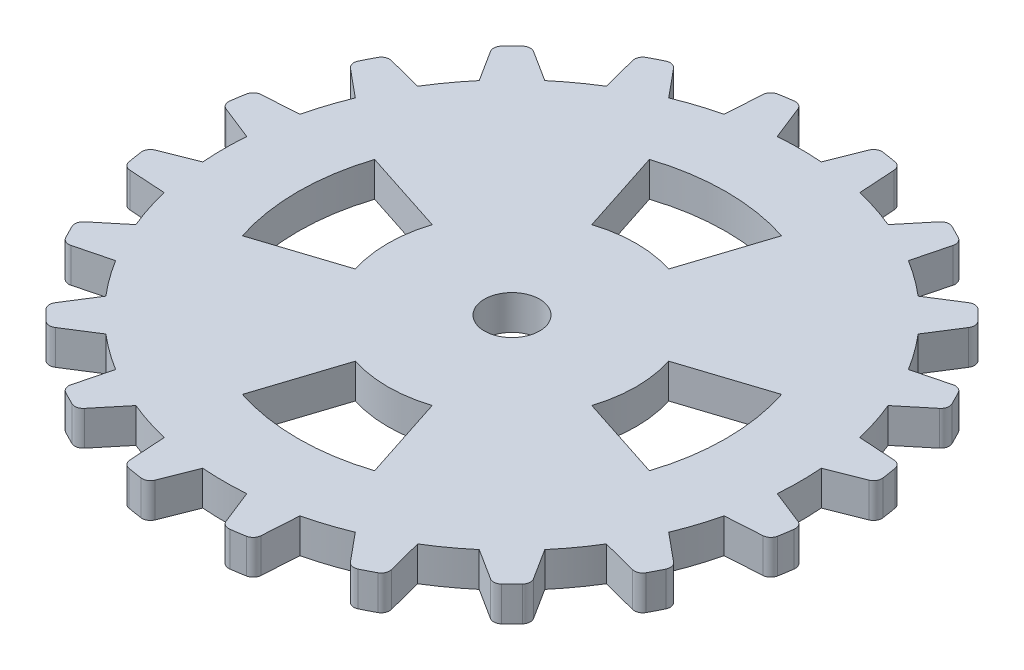
from build123d import *

# Parameters (mm, degrees)
BOSS_EXTRUDE1_DEPTH = 2.5
FILLET1_R           = 0.6
CUT_EXTRUDE1_DEPTH  = 3.5
SKETCH3_R           = 2
CUT_EXTRUDE2_DEPTH  = 3.5


with BuildPart() as part:
    # Sketch1 → Boss-Extrude1 (new body)
    with BuildSketch(Plane(origin=(0, 0, 0), x_dir=(1, 0, 0), z_dir=(0, 1, 0))):
        with BuildLine():
            Line((-1.594631361, 20.812249191), (-2.743922179, 23.715026443))
            ThreePointArc((-2.743922179, 23.715026443), (-3.734597528, 23.5793208), (-4.718721125, 23.402249017))
            Line((-4.718721125, 23.402249017), (-4.914754144, 20.286393402))
            ThreePointArc((-4.914754144, 20.286393402), (-6.450188978, 19.851640429), (-7.947923238, 19.300857021))
            Line((-7.947923238, 19.300857021), (-9.937971261, 21.706411848))
            ThreePointArc((-9.937971261, 21.706411848), (-10.838224158, 21.271212594), (-11.719463127, 20.798696404))
            Line((-11.719463127, 20.798696404), (-10.94304927, 17.774764084))
            ThreePointArc((-10.94304927, 17.774764084), (-12.268988517, 16.886813978), (-13.523217013, 15.90016249))
            Line((-13.523217013, 15.90016249), (-16.159222474, 17.573022424))
            ThreePointArc((-16.159222474, 17.573022424), (-16.880929893, 16.880929893), (-17.573022424, 16.159222474))
            Line((-17.573022424, 16.159222474), (-15.90016249, 13.523217013))
            ThreePointArc((-15.90016249, 13.523217013), (-16.886813978, 12.268988517), (-17.774764084, 10.94304927))
            Line((-17.774764084, 10.94304927), (-20.798696404, 11.719463127))
            ThreePointArc((-20.798696404, 11.719463127), (-21.271212594, 10.838224158), (-21.706411848, 9.937971261))
            Line((-21.706411848, 9.937971261), (-19.300857021, 7.947923238))
            ThreePointArc((-19.300857021, 7.947923238), (-19.851640429, 6.450188978), (-20.286393402, 4.914754144))
            Line((-20.286393402, 4.914754144), (-23.402249017, 4.718721125))
            ThreePointArc((-23.402249017, 4.718721125), (-23.5793208, 3.734597528), (-23.715026443, 2.743922179))
            Line((-23.715026443, 2.743922179), (-20.812249191, 1.594631361))
            ThreePointArc((-20.812249191, 1.594631361), (-20.87325, 0), (-20.812249191, -1.594631361))
            Line((-20.812249191, -1.594631361), (-23.715026443, -2.743922179))
            ThreePointArc((-23.715026443, -2.743922179), (-23.5793208, -3.734597528), (-23.402249017, -4.718721125))
            Line((-23.402249017, -4.718721125), (-20.286393402, -4.914754144))
            ThreePointArc((-20.286393402, -4.914754144), (-19.851640429, -6.450188978), (-19.300857021, -7.947923238))
            Line((-19.300857021, -7.947923238), (-21.706411848, -9.937971261))
            ThreePointArc((-21.706411848, -9.937971261), (-21.271212594, -10.838224158), (-20.798696404, -11.719463127))
            Line((-20.798696404, -11.719463127), (-17.774764084, -10.94304927))
            ThreePointArc((-17.774764084, -10.94304927), (-16.886813978, -12.268988517), (-15.90016249, -13.523217013))
            Line((-15.90016249, -13.523217013), (-17.573022424, -16.159222474))
            ThreePointArc((-17.573022424, -16.159222474), (-16.880929893, -16.880929893), (-16.159222474, -17.573022424))
            Line((-16.159222474, -17.573022424), (-13.523217013, -15.90016249))
            ThreePointArc((-13.523217013, -15.90016249), (-12.268988517, -16.886813978), (-10.94304927, -17.774764084))
            Line((-10.94304927, -17.774764084), (-11.719463127, -20.798696404))
            ThreePointArc((-11.719463127, -20.798696404), (-10.838224158, -21.271212594), (-9.937971261, -21.706411848))
            Line((-9.937971261, -21.706411848), (-7.947923238, -19.300857021))
            ThreePointArc((-7.947923238, -19.300857021), (-6.450188978, -19.851640429), (-4.914754144, -20.286393402))
            Line((-4.914754144, -20.286393402), (-4.718721125, -23.402249017))
            ThreePointArc((-4.718721125, -23.402249017), (-3.734597528, -23.5793208), (-2.743922179, -23.715026443))
            Line((-2.743922179, -23.715026443), (-1.594631361, -20.812249191))
            ThreePointArc((-1.594631361, -20.812249191), (0, -20.87325), (1.594631361, -20.812249191))
            Line((1.594631361, -20.812249191), (2.743922179, -23.715026443))
            ThreePointArc((2.743922179, -23.715026443), (3.734597528, -23.5793208), (4.718721125, -23.402249017))
            Line((4.718721125, -23.402249017), (4.914754144, -20.286393402))
            ThreePointArc((4.914754144, -20.286393402), (6.450188978, -19.851640429), (7.947923238, -19.300857021))
            Line((7.947923238, -19.300857021), (9.937971261, -21.706411848))
            ThreePointArc((9.937971261, -21.706411848), (10.838224158, -21.271212594), (11.719463127, -20.798696404))
            Line((11.719463127, -20.798696404), (10.94304927, -17.774764084))
            ThreePointArc((10.94304927, -17.774764084), (12.268988517, -16.886813978), (13.523217013, -15.90016249))
            Line((13.523217013, -15.90016249), (16.159222474, -17.573022424))
            ThreePointArc((16.159222474, -17.573022424), (16.880929893, -16.880929893), (17.573022424, -16.159222474))
            Line((17.573022424, -16.159222474), (15.90016249, -13.523217013))
            ThreePointArc((15.90016249, -13.523217013), (16.886813978, -12.268988517), (17.774764084, -10.94304927))
            Line((17.774764084, -10.94304927), (20.798696404, -11.719463127))
            ThreePointArc((20.798696404, -11.719463127), (21.271212594, -10.838224158), (21.706411848, -9.937971261))
            Line((21.706411848, -9.937971261), (19.300857021, -7.947923238))
            ThreePointArc((19.300857021, -7.947923238), (19.851640429, -6.450188978), (20.286393402, -4.914754144))
            Line((20.286393402, -4.914754144), (23.402249017, -4.718721125))
            ThreePointArc((23.402249017, -4.718721125), (23.5793208, -3.734597528), (23.715026443, -2.743922179))
            Line((23.715026443, -2.743922179), (20.812249191, -1.594631361))
            ThreePointArc((20.812249191, -1.594631361), (20.87325, 0), (20.812249191, 1.594631361))
            Line((20.812249191, 1.594631361), (23.715026443, 2.743922179))
            ThreePointArc((23.715026443, 2.743922179), (23.5793208, 3.734597528), (23.402249017, 4.718721125))
            Line((23.402249017, 4.718721125), (20.286393402, 4.914754144))
            ThreePointArc((20.286393402, 4.914754144), (19.851640429, 6.450188978), (19.300857021, 7.947923238))
            Line((19.300857021, 7.947923238), (21.706411848, 9.937971261))
            ThreePointArc((21.706411848, 9.937971261), (21.271212594, 10.838224158), (20.798696404, 11.719463127))
            Line((20.798696404, 11.719463127), (17.774764084, 10.94304927))
            ThreePointArc((17.774764084, 10.94304927), (16.886813978, 12.268988517), (15.90016249, 13.523217013))
            Line((15.90016249, 13.523217013), (17.573022424, 16.159222474))
            ThreePointArc((17.573022424, 16.159222474), (16.880929893, 16.880929893), (16.159222474, 17.573022424))
            Line((16.159222474, 17.573022424), (13.523217013, 15.90016249))
            ThreePointArc((13.523217013, 15.90016249), (12.268988517, 16.886813978), (10.94304927, 17.774764084))
            Line((10.94304927, 17.774764084), (11.719463127, 20.798696404))
            ThreePointArc((11.719463127, 20.798696404), (10.838224158, 21.271212594), (9.937971261, 21.706411848))
            Line((9.937971261, 21.706411848), (7.947923238, 19.300857021))
            ThreePointArc((7.947923238, 19.300857021), (6.450188978, 19.851640429), (4.914754144, 20.286393402))
            Line((4.914754144, 20.286393402), (4.718721125, 23.402249017))
            ThreePointArc((4.718721125, 23.402249017), (3.734597528, 23.5793208), (2.743922179, 23.715026443))
            Line((2.743922179, 23.715026443), (1.594631361, 20.812249191))
            ThreePointArc((1.594631361, 20.812249191), (0, 20.87325), (-1.594631361, 20.812249191))
        make_face()
    extrude(amount=-BOSS_EXTRUDE1_DEPTH)

    # Fillet1
    fillet1_edges = [part.edges().sort_by_distance(p)[0] for p in [
        (2.743922179, -1.25, -23.715026443),
        (4.718721125, -1.25, -23.402249017),
        (9.937971261, -1.25, -21.706411848),
        (11.719463127, -1.25, -20.798696404),
        (16.159222474, -1.25, -17.573022424),
        (17.573022424, -1.25, -16.159222474),
        (20.798696404, -1.25, -11.719463127),
        (21.706411848, -1.25, -9.937971261),
        (23.402249017, -1.25, -4.718721125),
        (23.715026443, -1.25, -2.743922179),
        (23.715026443, -1.25, 2.743922179),
        (23.402249017, -1.25, 4.718721125),
        (21.706411848, -1.25, 9.937971261),
        (20.798696404, -1.25, 11.719463127),
        (17.573022424, -1.25, 16.159222474),
        (16.159222474, -1.25, 17.573022424),
        (11.719463127, -1.25, 20.798696404),
        (9.937971261, -1.25, 21.706411848),
        (4.718721125, -1.25, 23.402249017),
        (2.743922179, -1.25, 23.715026443),
        (-2.743922179, -1.25, 23.715026443),
        (-4.718721125, -1.25, 23.402249017),
        (-9.937971261, -1.25, 21.706411848),
        (-11.719463127, -1.25, 20.798696404),
        (-16.159222474, -1.25, 17.573022424),
        (-17.573022424, -1.25, 16.159222474),
        (-20.798696404, -1.25, 11.719463127),
        (-21.706411848, -1.25, 9.937971261),
        (-23.402249017, -1.25, 4.718721125),
        (-23.715026443, -1.25, 2.743922179),
        (-23.715026443, -1.25, -2.743922179),
        (-23.402249017, -1.25, -4.718721125),
        (-21.706411848, -1.25, -9.937971261),
        (-20.798696404, -1.25, -11.719463127),
        (-17.573022424, -1.25, -16.159222474),
        (-16.159222474, -1.25, -17.573022424),
        (-11.719463127, -1.25, -20.798696404),
        (-9.937971261, -1.25, -21.706411848),
        (-4.718721125, -1.25, -23.402249017),
        (-2.743922179, -1.25, -23.715026443),
    ]]
    fillet(fillet1_edges, radius=FILLET1_R)

    # Sketch2 → Cut-Extrude1 (cut, through all)
    with BuildSketch(Plane.XZ.offset(2.5)):
        with BuildLine():
            ThreePointArc((-4.789763413, -14.741376003), (0, -15.5), (4.789763413, -14.741376003))
            Line((4.789763413, -14.741376003), (2.781152949, -8.559508647))
            ThreePointArc((2.781152949, -8.559508647), (0, -9), (-2.781152949, -8.559508647))
            Line((-2.781152949, -8.559508647), (-4.789763413, -14.741376003))
        make_face()
        with BuildLine():
            Line((8.559508647, -2.781152949), (14.741376003, -4.789763413))
            ThreePointArc((14.741376003, -4.789763413), (15.309169279, -2.424734208), (15.5, 0))
            ThreePointArc((15.5, 0), (15.309169279, 2.424734208), (14.741376003, 4.789763413))
            Line((14.741376003, 4.789763413), (8.559508647, 2.781152949))
            ThreePointArc((8.559508647, 2.781152949), (8.889195065, 1.407910185), (9, 0))
            ThreePointArc((9, 0), (8.889195065, -1.407910185), (8.559508647, -2.781152949))
        make_face()
        with BuildLine():
            Line((2.781152949, 8.559508647), (4.789763413, 14.741376003))
            ThreePointArc((4.789763413, 14.741376003), (0, 15.5), (-4.789763413, 14.741376003))
            Line((-4.789763413, 14.741376003), (-2.781152949, 8.559508647))
            ThreePointArc((-2.781152949, 8.559508647), (0, 9), (2.781152949, 8.559508647))
        make_face()
        with BuildLine():
            ThreePointArc((-14.741376003, 4.789763413), (-15.5, 0), (-14.741376003, -4.789763413))
            Line((-14.741376003, -4.789763413), (-8.559508647, -2.781152949))
            ThreePointArc((-8.559508647, -2.781152949), (-9, 0), (-8.559508647, 2.781152949))
            Line((-8.559508647, 2.781152949), (-14.741376003, 4.789763413))
        make_face()
    extrude(amount=-CUT_EXTRUDE1_DEPTH, mode=Mode.SUBTRACT)

    # Sketch3 → Cut-Extrude2 (cut, through all)
    with BuildSketch(Plane.XZ.offset(2.5)):
        Circle(SKETCH3_R)
    extrude(amount=-CUT_EXTRUDE2_DEPTH, mode=Mode.SUBTRACT)


solid = part.part
